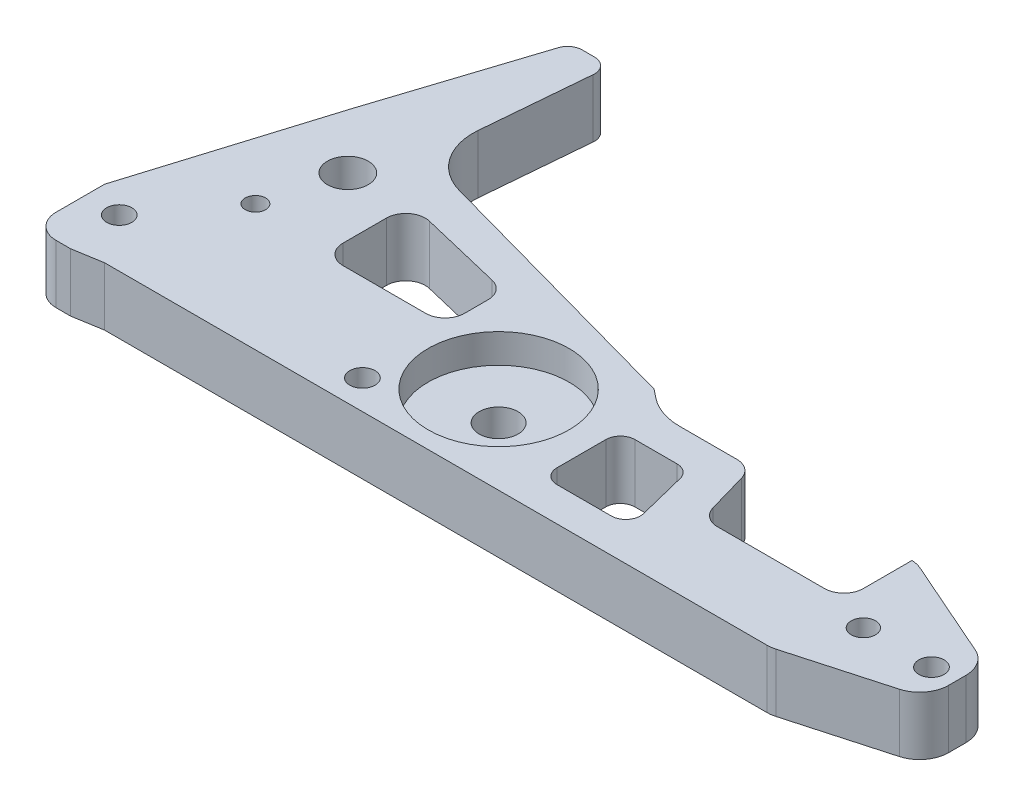
from build123d import *

# Parameters (mm, degrees)
SKETCH1_R           = 2.6
SKETCH1_R_2         = 2.1
SKETCH1_R_3         = 4.2
SKETCH1_R_4         = 2.5
BOSS_EXTRUDE1_DEPTH = 12
FILLET2_R           = 6
FILLET3_R           = 3
CUT_EXTRUDE1_DEPTH  = 13
SKETCH5_R           = 4
CUT_EXTRUDE2_DEPTH  = 13
SKETCH6_R           = 14.5
CUT_EXTRUDE3_DEPTH  = 6
FILLET4_R           = 12
SKETCH7_R           = 2.6
CUT_EXTRUDE4_DEPTH  = 13
FILLET6_R           = 3
FILLET8_R           = 5
FILLET9_R           = 4
CUT_EXTRUDE6_DEPTH  = 13
FILLET10_R          = 4


with BuildPart() as part:
    # Sketch1 → Boss-Extrude1 (new body)
    with BuildSketch(Plane(origin=(0, 0, 0), x_dir=(1, 0, 0), z_dir=(0, 1, 0))):
        Polygon((162, 19), (137, 30), (83.968719423, 30), (78.968719423, 34), (13.968719423, 52), (17, 87), (9, 87), (-2, 53), (-14, 14), (-14, 2), (-14, -1), (-6, -1), (0, 0), (137, 0), (162, 7), align=None)
        with Locations((-7, 10)):
            Circle(SKETCH1_R, mode=Mode.SUBTRACT)
        with Locations((157, 13)):
            Circle(SKETCH1_R, mode=Mode.SUBTRACT)
        with Locations((5, 26)):
            Circle(SKETCH1_R_2, mode=Mode.SUBTRACT)
        with Locations((9, 41)):
            Circle(SKETCH1_R_3, mode=Mode.SUBTRACT)
        with Locations((143, 13)):
            Circle(SKETCH1_R_4, mode=Mode.SUBTRACT)
    extrude(amount=BOSS_EXTRUDE1_DEPTH)

    # Fillet2
    fillet2_edges = [part.edges().sort_by_distance(p)[0] for p in [
        (137, 6, -30),
        (162, 6, -19),
        (162, 6, -7),
        (137, 6, 0),
    ]]
    fillet(fillet2_edges, radius=FILLET2_R)

    # Fillet3
    fillet3_edges = [part.edges().sort_by_distance(p)[0] for p in [
        (9, 6, -87),
        (17, 6, -87),
    ]]
    fillet(fillet3_edges, radius=FILLET3_R)

    # Sketch4 → Cut-Extrude1 (cut, through all)
    with BuildSketch(Plane(origin=(0, 12, 0), x_dir=(1, 0, 0), z_dir=(0, 1, 0))):
        Polygon((21, 42), (21, 24), (46, 24), (46, 36), align=None)
        Polygon((97, 23.043498828), (83, 23.043498828), (83, 7), (101, 7), align=None)
    extrude(amount=-CUT_EXTRUDE1_DEPTH, mode=Mode.SUBTRACT)

    # Sketch5 → Cut-Extrude2 (cut, through all)
    with BuildSketch(Plane(origin=(0, 12, 0), x_dir=(1, 0, 0), z_dir=(0, 1, 0))):
        with Locations((63, 18)):
            Circle(SKETCH5_R)
    extrude(amount=-CUT_EXTRUDE2_DEPTH, mode=Mode.SUBTRACT)

    # Sketch6 → Cut-Extrude3 (cut)
    with BuildSketch(Plane(origin=(0, 12, 0), x_dir=(1, 0, 0), z_dir=(0, 1, 0))):
        with Locations((63, 18)):
            Circle(SKETCH6_R)
    extrude(amount=-CUT_EXTRUDE3_DEPTH, mode=Mode.SUBTRACT)

    # Fillet4
    fillet4_edges = [part.edges().sort_by_distance(p)[0] for p in [
        (13.968719423, 6, -52),
        (83.968719423, 6, -30),
    ]]
    fillet(fillet4_edges, radius=FILLET4_R)

    # Sketch7 → Cut-Extrude4 (cut, through all)
    with BuildSketch(Plane(origin=(0, 12, 0), x_dir=(1, 0, 0), z_dir=(0, 1, 0))):
        with Locations((47, 6)):
            Circle(SKETCH7_R)
    extrude(amount=-CUT_EXTRUDE4_DEPTH, mode=Mode.SUBTRACT)

    # Fillet6
    fillet6_edges = [part.edges().sort_by_distance(p)[0] for p in [
        (97, 6, -23.043498828),
        (101, 6, -7),
        (83, 6, -7),
        (83, 6, -23.043498828),
    ]]
    fillet(fillet6_edges, radius=FILLET6_R)

    # Fillet8
    fillet8_edges = [part.edges().sort_by_distance(p)[0] for p in [
        (-14, 6, 1),
    ]]
    fillet(fillet8_edges, radius=FILLET8_R)

    # Fillet9
    fillet9_edges = [part.edges().sort_by_distance(p)[0] for p in [
        (21, 6, -42),
        (46, 6, -36),
        (46, 6, -24),
        (21, 6, -24),
    ]]
    fillet(fillet9_edges, radius=FILLET9_R)

    # Sketch10 → Cut-Extrude6 (cut, through all)
    with BuildSketch(Plane(origin=(0, 12, 0), x_dir=(1, 0, 0), z_dir=(0, 1, 0))):
        Polygon((103, 30), (107, 16), (136, 16), (136, 30), align=None)
    extrude(amount=-CUT_EXTRUDE6_DEPTH, mode=Mode.SUBTRACT)

    # Fillet10
    fillet10_edges = [part.edges().sort_by_distance(p)[0] for p in [
        (103, 6, -30),
        (136, 6, -16),
        (107, 6, -16),
    ]]
    fillet(fillet10_edges, radius=FILLET10_R)


solid = part.part
